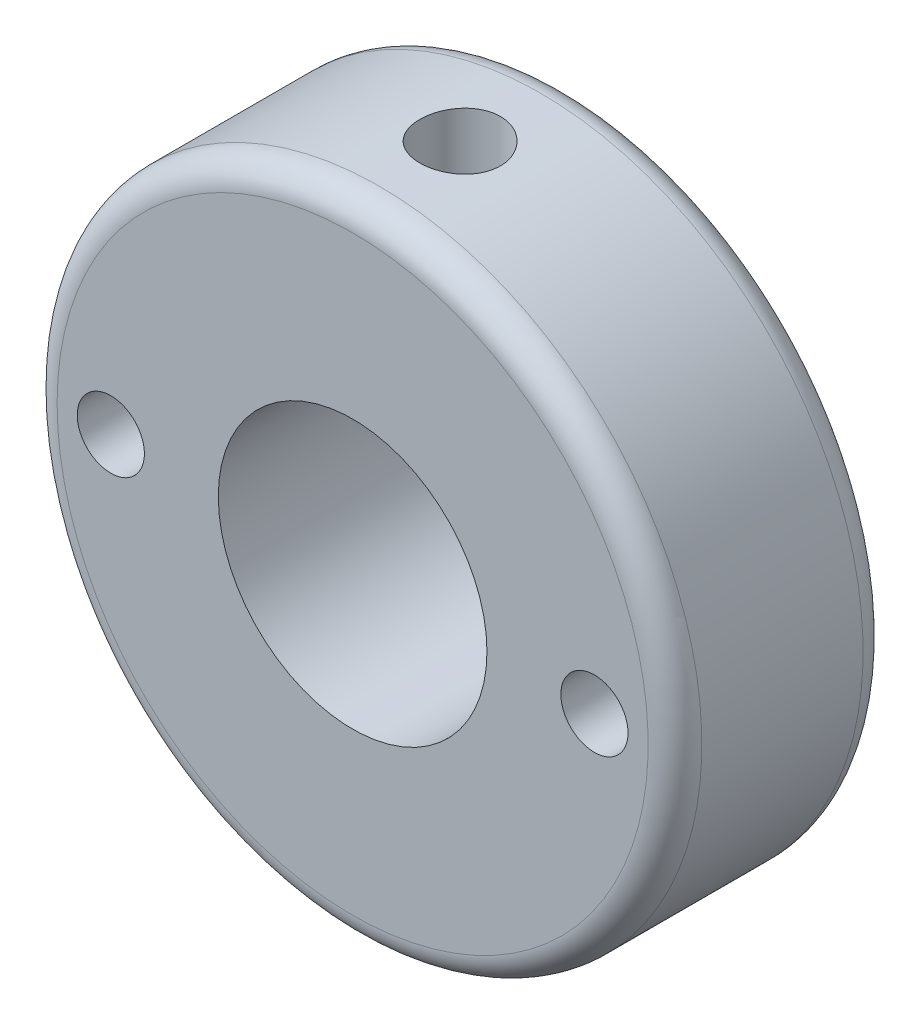
from build123d import *

# Parameters (mm, degrees)
SKETCH1_W                  = 24
SKETCH1_H                  = 24
BOSS_EXTRUDE1_DEPTH        = 8
M3_TAPPED_HOLE1_D          = 2.5
F_10_0_10_DIAMETER_HOLE1_D = 10
F_3_0MM_DOWEL_HOLE1_REACH  = 30
F_3_0MM_DOWEL_HOLE1_BORE_R = 1.5
SKETCH15_R                 = 16.970562748
SKETCH15_R_2               = 12
CUT_EXTRUDE1_DEPTH         = 10
FILLET1_R                  = 1


with BuildPart() as part:
    # Sketch1 → Boss-Extrude1 (new body)
    with BuildSketch(Plane.XY):
        Rectangle(SKETCH1_W, SKETCH1_H)
    extrude(amount=BOSS_EXTRUDE1_DEPTH)

    # M3 Tapped Hole1 (through all)
    with Locations(Plane.XY.offset(8)):
        with Locations((9, 0), (-9, 0)):
            Hole(M3_TAPPED_HOLE1_D / 2)

    # Ø10.0 (10) Diameter Hole1 (through all)
    with Locations(Plane(origin=(0, 0, 0), x_dir=(-1, 0, 0), z_dir=(0, 0, -1))):
        with Locations((0, 0)):
            Hole(F_10_0_10_DIAMETER_HOLE1_D / 2)

    # Ø3.0mm Dowel Hole1 bore → Ø3.0mm Dowel Hole1 (cut, up to next)
    with BuildSketch(Plane(origin=(0, 12, 0), x_dir=(1, 0, 0), z_dir=(0, 1, 0)), mode=Mode.PRIVATE) as f_3_0mm_dowel_hole1_sk1:
        with Locations((0, -4)):
            Circle(F_3_0MM_DOWEL_HOLE1_BORE_R)
    f_3_0mm_dowel_hole1_tool1 = extrude(f_3_0mm_dowel_hole1_sk1.sketch, amount=-F_3_0MM_DOWEL_HOLE1_REACH, mode=Mode.PRIVATE) & part.part
    add(f_3_0mm_dowel_hole1_tool1.solids().sort_by_distance((0, 12, 4))[0], mode=Mode.SUBTRACT)

    # Sketch15 → Cut-Extrude1 (cut)
    with BuildSketch(Plane.XY.offset(8)):
        Circle(SKETCH15_R)
        Circle(SKETCH15_R_2, mode=Mode.SUBTRACT)
    extrude(amount=-CUT_EXTRUDE1_DEPTH, mode=Mode.SUBTRACT)

    # Fillet1
    fillet1_edges = [part.edges().sort_by_distance(p)[0] for p in [
        (-12, 0, 0),
        (-12, 0, 8),
    ]]
    fillet(fillet1_edges, radius=FILLET1_R)


solid = part.part
